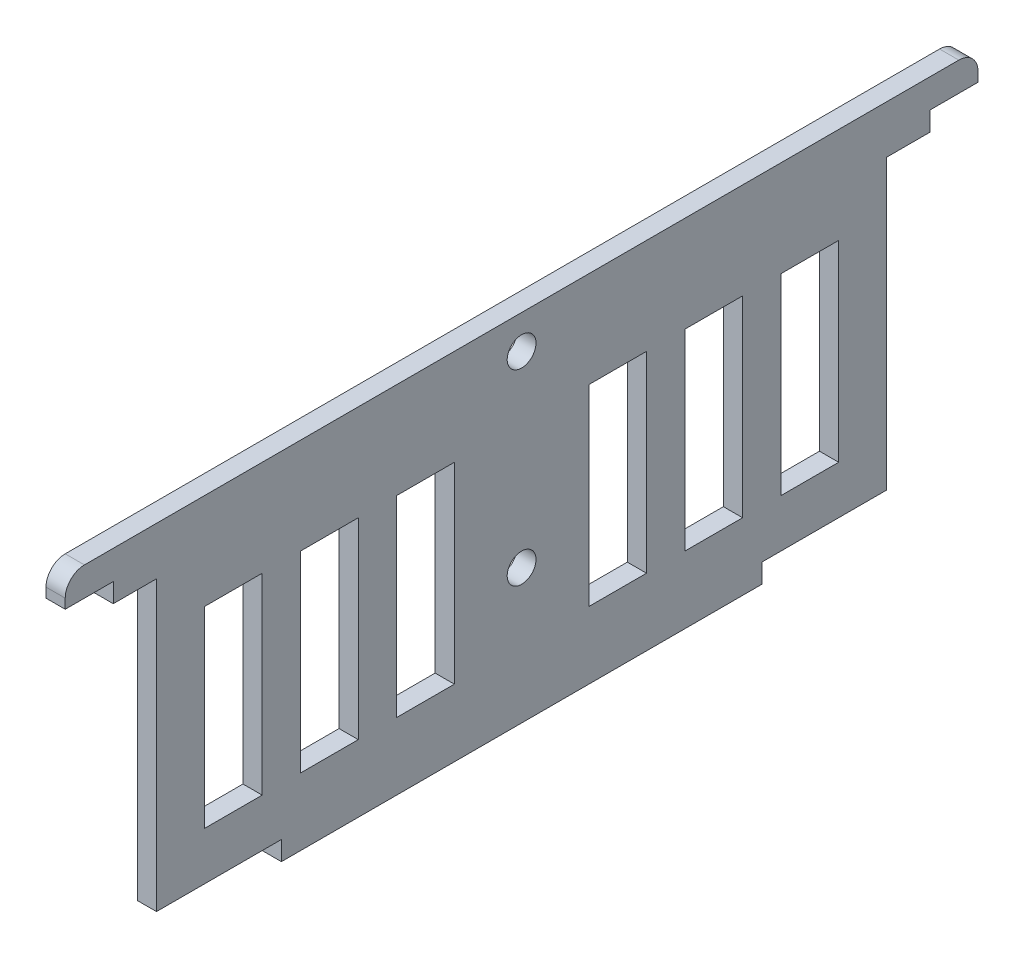
from build123d import *

# Parameters (mm, degrees)
SKETCH1_R           = 1.5
SKETCH1_W           = 6
SKETCH1_H           = 20
BOSS_EXTRUDE1_DEPTH = 2
FILLET2_R           = 2


with BuildPart() as part:
    # Sketch1 → Boss-Extrude1 (new body)
    with BuildSketch(Plane(origin=(0, 0, 0), x_dir=(0, 0, -1), z_dir=(1, 0, 0))):
        Polygon((-25, -15), (-25, -17), (25, -17), (25, -15), (38, -15), (38, 15), (42.5, 15), (42.5, 17), (47.5, 17), (47.5, 20), (-47.5, 20), (-47.5, 17), (-42.5, 17), (-42.5, 15), (-38, 15), (-38, -15), align=None)
        with Locations((0, 16.5)):
            Circle(SKETCH1_R, mode=Mode.SUBTRACT)
        with Locations((0, -3)):
            Circle(SKETCH1_R, mode=Mode.SUBTRACT)
        with Locations((20, 0)):
            Rectangle(SKETCH1_W, SKETCH1_H, mode=Mode.SUBTRACT)
        with Locations((30, 0)):
            Rectangle(SKETCH1_W, SKETCH1_H, mode=Mode.SUBTRACT)
        with Locations((10, 0)):
            Rectangle(SKETCH1_W, SKETCH1_H, mode=Mode.SUBTRACT)
        with Locations((-10, 0)):
            Rectangle(SKETCH1_W, SKETCH1_H, mode=Mode.SUBTRACT)
        with Locations((-20, 0)):
            Rectangle(SKETCH1_W, SKETCH1_H, mode=Mode.SUBTRACT)
        with Locations((-30, 0)):
            Rectangle(SKETCH1_W, SKETCH1_H, mode=Mode.SUBTRACT)
    extrude(amount=BOSS_EXTRUDE1_DEPTH)

    # Fillet2
    fillet2_edges = [part.edges().sort_by_distance(p)[0] for p in [
        (1, 20, 47.5),
        (1, 20, -47.5),
    ]]
    fillet(fillet2_edges, radius=FILLET2_R)


solid = part.part
